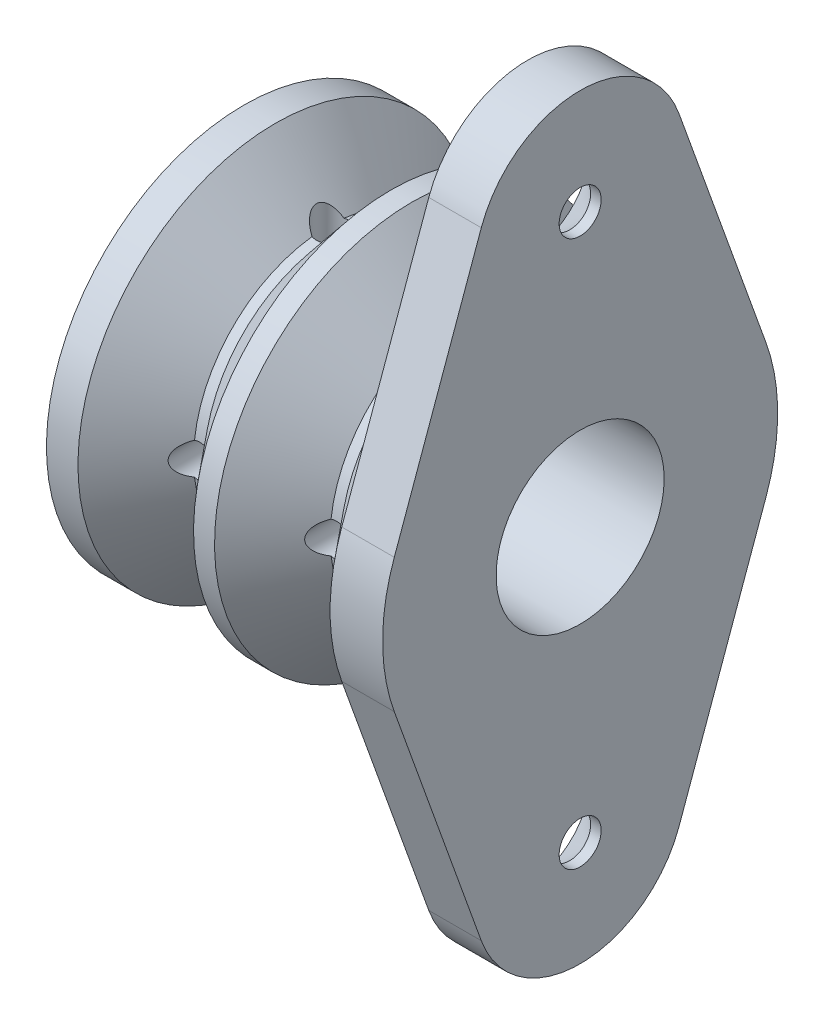
from build123d import *

# Parameters (mm, degrees)
BOSS_EXTRUDE1_START     = 6
SKETCH4_R               = 1
BOSS_EXTRUDE1_DEPTH     = 2.5
SKETCH6_R               = 0.8
CUT_EXTRUDE2_DEPTH      = 19
CIRPATTERN1_COUNT       = 2
CIRPATTERN1_ANGLE       = 90
CHAMFER1_SIZE           = 2
SKETCH7_R               = 4
CUT_EXTRUDE3_DEPTH      = 9.5
CUT_EXTRUDE3_DEPTH_BACK = 8.5


with BuildPart() as part:
    # Sketch1 → Revolve1 (revolve)
    with BuildSketch(Plane.XY):
        Polygon((0, 0), (0, 9.4), (0.5, 9.4), (3, 6.4), (3.5, 6.4), (6, 9.4), (7.5, 9.4), (7.5, 0), align=None)
    revolve1 = revolve(axis=Axis((7.5, 0, 0), (-1, 0, 0)))

    # Mirror1: Revolve1 across plane
    add(revolve1.mirror(Plane(origin=(0, 0, 0), x_dir=(0, 0, 1), z_dir=(1, 0, 0))))

    # Sketch4 → Boss-Extrude1 (add)
    with BuildSketch(Plane(origin=(0, 0, 0), x_dir=(0, 0, -1), z_dir=(1, 0, 0)).offset(BOSS_EXTRUDE1_START)):
        with BuildLine():
            Line((-4.704901133, 14.692307692), (-8.845214131, 3.181538462))
            ThreePointArc((-8.845214131, 3.181538462), (-9.4, 0), (-8.845214131, -3.181538462))
            Line((-8.845214131, -3.181538462), (-4.704901133, -14.692307692))
            ThreePointArc((-4.704901133, -14.692307692), (0, -18), (4.704901133, -14.692307692))
            Line((4.704901133, -14.692307692), (8.845214131, -3.181538462))
            ThreePointArc((8.845214131, -3.181538462), (9.4, 0), (8.845214131, 3.181538462))
            Line((8.845214131, 3.181538462), (4.704901133, 14.692307692))
            ThreePointArc((4.704901133, 14.692307692), (0, 18), (-4.704901133, 14.692307692))
        make_face()
        with Locations((0, -13)):
            Circle(SKETCH4_R, mode=Mode.SUBTRACT)
        with Locations((0, 13)):
            Circle(SKETCH4_R, mode=Mode.SUBTRACT)
    extrude(amount=BOSS_EXTRUDE1_DEPTH)

    # Sketch6 → Cut-Extrude2 (cut, symmetric)
    with BuildSketch(Plane(origin=(0, 0, 0), x_dir=(1, 0, 0), z_dir=(0, 1, 0))):
        with Locations((-3.25, 0)):
            Circle(SKETCH6_R)
        with Locations((3.25, 0)):
            Circle(SKETCH6_R)
    cut_extrude2 = extrude(amount=CUT_EXTRUDE2_DEPTH, both=True, mode=Mode.SUBTRACT)

    # CirPattern1: Cut-Extrude2 ×2 about axis
    cirpattern1_axis = Axis((-7.5, 0, 0), (1, 0, 0))
    for i in range(1, CIRPATTERN1_COUNT):
        add(cut_extrude2.rotate(cirpattern1_axis, i * CIRPATTERN1_ANGLE / (CIRPATTERN1_COUNT - 1)), mode=Mode.SUBTRACT)

    # Chamfer1
    chamfer1_edges = [part.edges().sort_by_distance(p)[0] for p in [
        (6, -13, 1),
        (6, 13, 1),
    ]]
    chamfer(chamfer1_edges, length=CHAMFER1_SIZE)

    # Sketch7 → Cut-Extrude3 (cut, two sides)
    with BuildSketch(Plane(origin=(0, 0, 0), x_dir=(0, 0, -1), z_dir=(1, 0, 0))) as cut_extrude3_sk:
        Circle(SKETCH7_R)
    extrude(amount=CUT_EXTRUDE3_DEPTH, mode=Mode.SUBTRACT)
    extrude(cut_extrude3_sk.sketch, amount=-CUT_EXTRUDE3_DEPTH_BACK, mode=Mode.SUBTRACT)


solid = part.part
